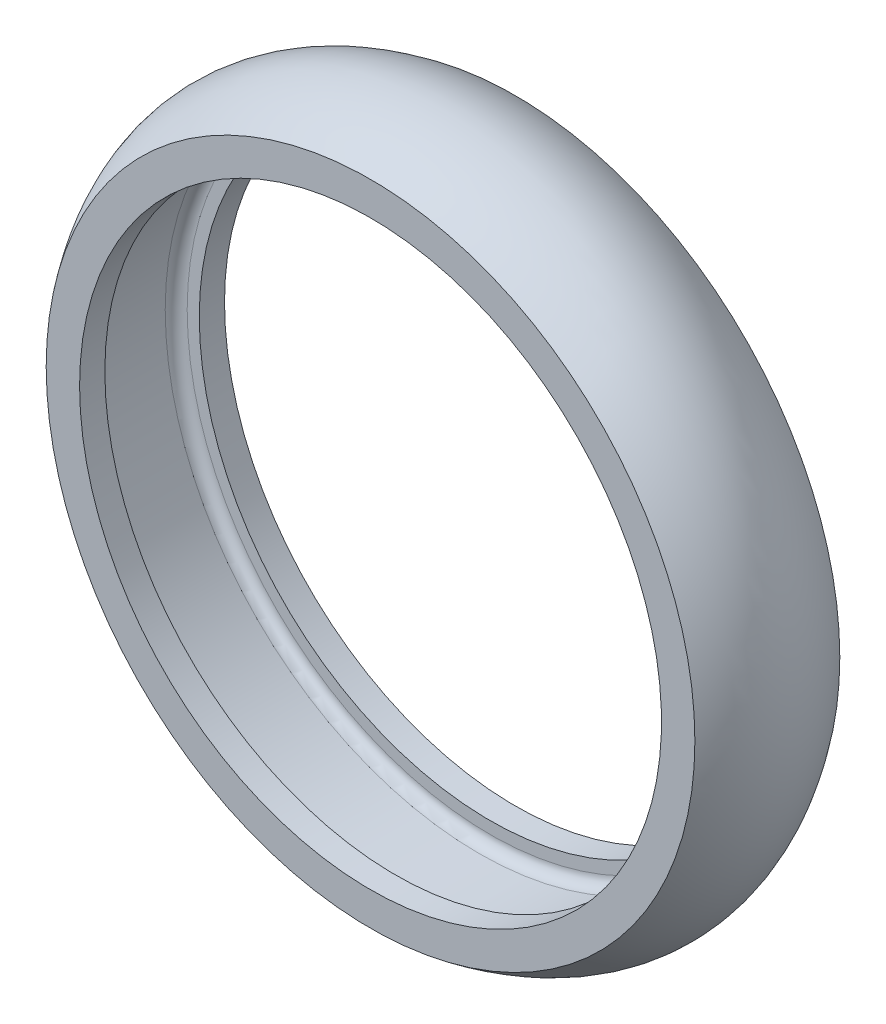
from build123d import *


with BuildPart() as part:
    # Croquis1 → Revolución1 (revolve)
    with BuildSketch(Plane(origin=(0, 0, 0), x_dir=(1, 0, 0), z_dir=(0, 1, 0))):
        with BuildLine():
            Line((14.3, 1.65), (14.3, -1.65))
            ThreePointArc((14.3, -1.65), (14.153553391, -2.003553391), (13.8, -2.15))
            Line((13.8, -2.15), (13.25, -2.15))
            Line((13.25, -2.15), (13.25, -3.3))
            Line((13.25, -3.3), (14.3, -3.3))
            Line((14.3, -3.3), (14.770844965, -3.3))
            add(Edge.make_bspline(
                [(14.770844965, 3.3), (17.229155035, 0), (14.770844965, -3.3)],
                knots=[0, 0, 0, 1, 1, 1], degree=2))
            Line((14.770844965, 3.3), (14.3, 3.3))
            Line((14.3, 3.3), (13.25, 3.3))
            Line((13.25, 3.3), (13.25, 2.15))
            Line((13.25, 2.15), (13.8, 2.15))
            ThreePointArc((13.8, 2.15), (14.153553391, 2.003553391), (14.3, 1.65))
        make_face()
    revolve(axis=Axis((0, 0, -4.621416215), (0, 0, 1)))


solid = part.part
